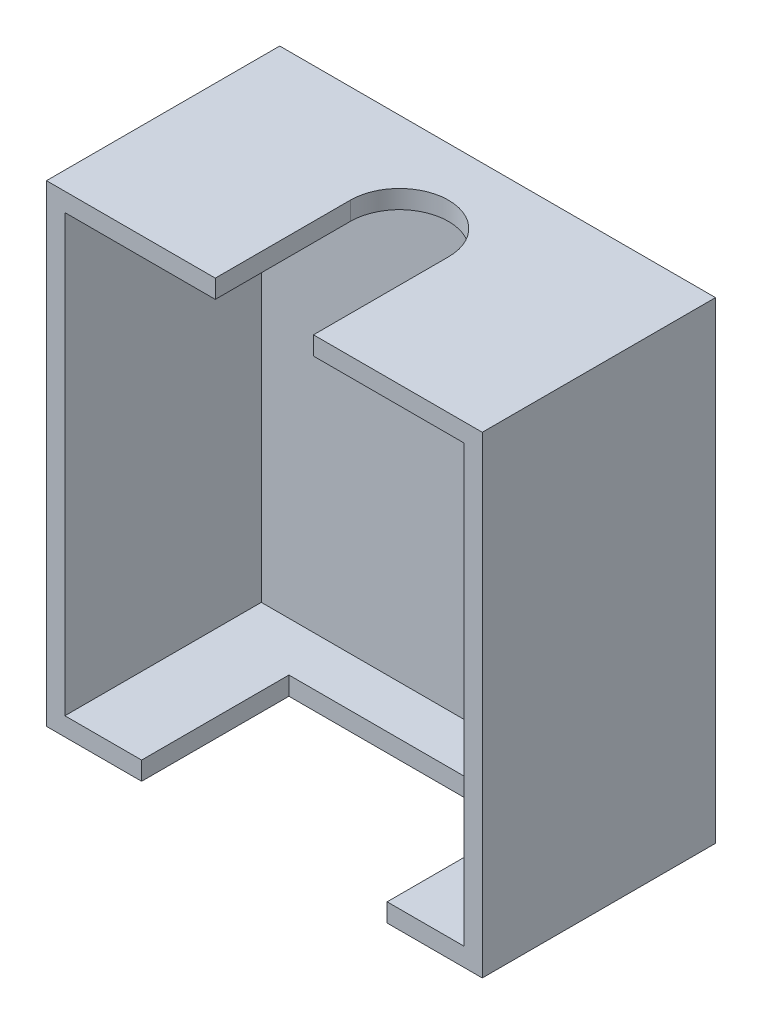
from build123d import *

# Parameters (mm, degrees)
ESQUISSE1_W             = 35.5
ESQUISSE1_H             = 38.5
BOSS_EXTRU_1_DEPTH      = 19
ESQUISSE3_W             = 32.5
ESQUISSE3_H             = 35.5
ENL_V_MAT_EXTRU_1_DEPTH = 16
ESQUISSE4_R             = 4
ENL_V_MAT_EXTRU_2_DEPTH = 5
ESQUISSE5_W             = 20
ESQUISSE5_H             = 12
ENL_V_MAT_EXTRU_3_DEPTH = 5


with BuildPart() as part:
    # Esquisse1 → Boss.-Extru.1 (new body)
    with BuildSketch(Plane.XY):
        Rectangle(ESQUISSE1_W, ESQUISSE1_H)
    extrude(amount=BOSS_EXTRU_1_DEPTH)

    # Esquisse3 → Enlèv. mat.-Extru.1 (cut)
    with BuildSketch(Plane.XY.offset(19)):
        Rectangle(ESQUISSE3_W, ESQUISSE3_H)
    extrude(amount=-ENL_V_MAT_EXTRU_1_DEPTH, mode=Mode.SUBTRACT)

    # Esquisse4 → Enlèv. mat.-Extru.2 (cut)
    with BuildSketch(Plane(origin=(0, 19.25, 0), x_dir=(1, 0, 0), z_dir=(0, 1, 0))):
        with BuildLine():
            ThreePointArc((4, -8), (0, -12), (-4, -8))
            Line((-4, -8), (-4, -19))
            Line((-4, -19), (4, -19))
            Line((4, -19), (4, -8))
        make_face()
        with Locations((0, -8)):
            Circle(ESQUISSE4_R)
    extrude(amount=-ENL_V_MAT_EXTRU_2_DEPTH, mode=Mode.SUBTRACT)

    # Esquisse5 → Enlèv. mat.-Extru.3 (cut)
    with BuildSketch(Plane.XZ.offset(19.25)):
        with Locations((0, 13)):
            Rectangle(ESQUISSE5_W, ESQUISSE5_H)
    extrude(amount=-ENL_V_MAT_EXTRU_3_DEPTH, mode=Mode.SUBTRACT)


solid = part.part
